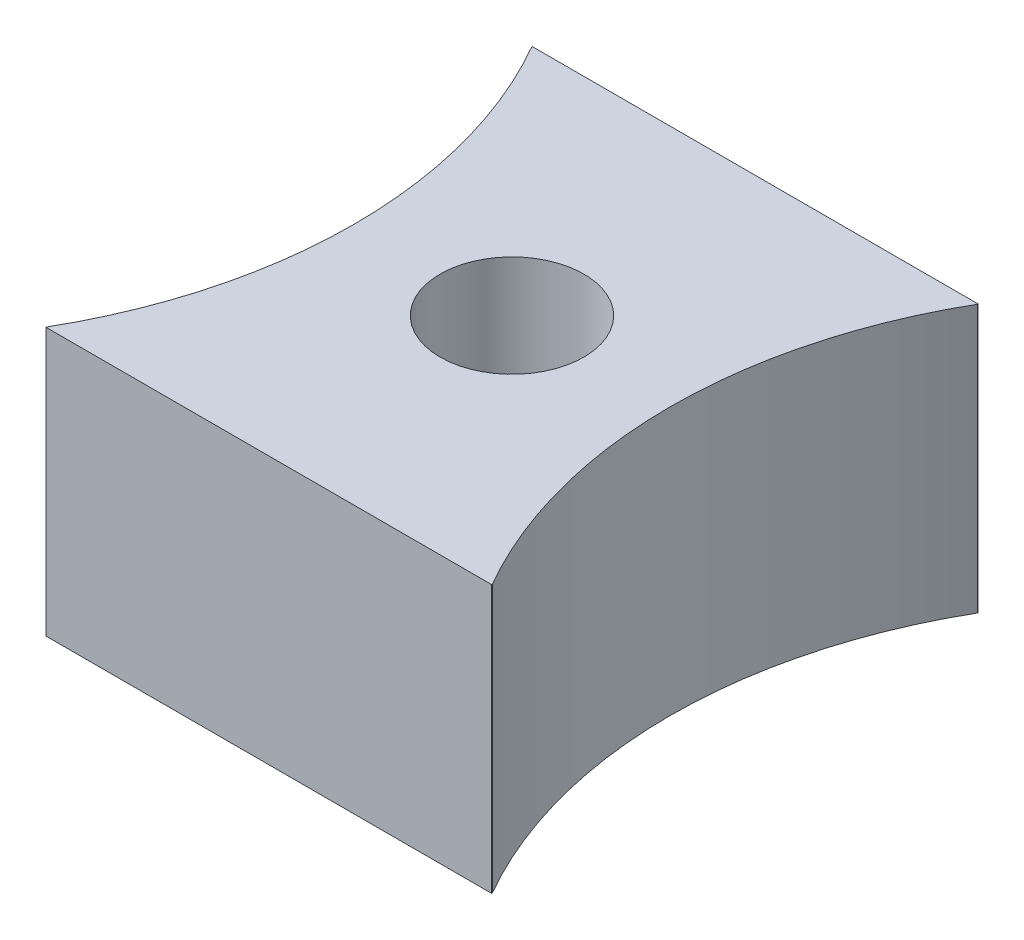
from build123d import *

# Parameters (mm, degrees)
SKETCH1_W           = 11
SKETCH1_H           = 12
BOSS_EXTRUDE1_DEPTH = 6.6
CUT_EXTRUDE1_DEPTH  = 6.6


with BuildPart() as part:
    # Sketch1 → Boss-Extrude1 (new body)
    with BuildSketch(Plane(origin=(0, 0, 0), x_dir=(1, 0, 0), z_dir=(0, 1, 0))):
        with Locations((5.5, -6)):
            Rectangle(SKETCH1_W, SKETCH1_H)
    extrude(amount=BOSS_EXTRUDE1_DEPTH)

    # Sketch2 → Cut-Extrude1 (cut)
    with BuildSketch(Plane(origin=(0, 6.6, 0), x_dir=(1, 0, 0), z_dir=(0, 1, 0))):
        with BuildLine():
            ThreePointArc((11, -0.013348181), (9.4, -6), (11, -11.986651819))
            Line((11, -11.986651819), (11, -0.013348181))
        make_face()
        with BuildLine():
            ThreePointArc((0, -11.986651819), (1.6, -6), (0, -0.013348181))
            Line((0, -0.013348181), (0, -11.986651819))
        make_face()
        with BuildLine():
            ThreePointArc((7.275, -6), (6.755114537, -4.744885463), (5.5, -4.225))
            Line((5.5, -4.225), (5.5, -7.775))
            ThreePointArc((5.5, -7.775), (6.755114537, -7.255114537), (7.275, -6))
        make_face()
        with BuildLine():
            Line((5.5, -7.775), (5.5, -4.225))
            ThreePointArc((5.5, -4.225), (3.725, -6), (5.5, -7.775))
        make_face()
    extrude(amount=-CUT_EXTRUDE1_DEPTH, mode=Mode.SUBTRACT)


solid = part.part
